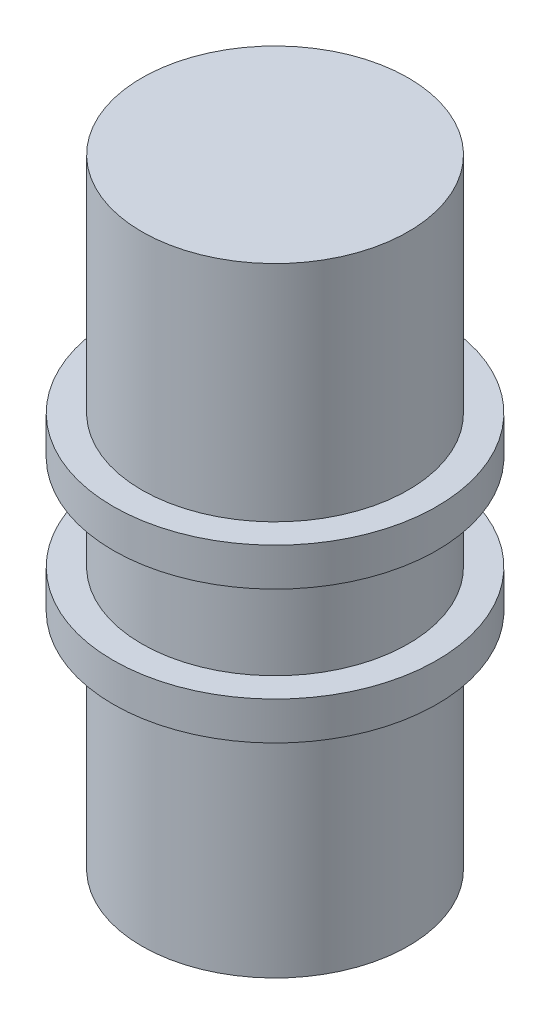
from build123d import *

# Parameters (mm, degrees)
SKETCH_1_R      = 7
EXTRUDE_1_DEPTH = 16.25
EXTRUDE_START   = 2.5
SKETCH_2_R      = 8.5
EXTRUDE_2_DEPTH = 2


with BuildPart() as part:
    # 草图1 → 凸台-拉伸1 (new body, symmetric)
    with BuildSketch(Plane(origin=(0, 0, 0), x_dir=(1, 0, 0), z_dir=(0, 1, 0))):
        Circle(SKETCH_1_R)
    extrude(amount=EXTRUDE_1_DEPTH, both=True)

    # 草图2 → 凸台-拉伸2 (add)
    with BuildSketch(Plane(origin=(0, 0, 0), x_dir=(1, 0, 0), z_dir=(0, 1, 0)).offset(EXTRUDE_START)):
        Circle(SKETCH_2_R)
    extrude_2 = extrude(amount=EXTRUDE_2_DEPTH)

    # 镜向1: 凸台-拉伸2 across plane
    add(extrude_2.mirror(Plane.ZX))


solid = part.part
